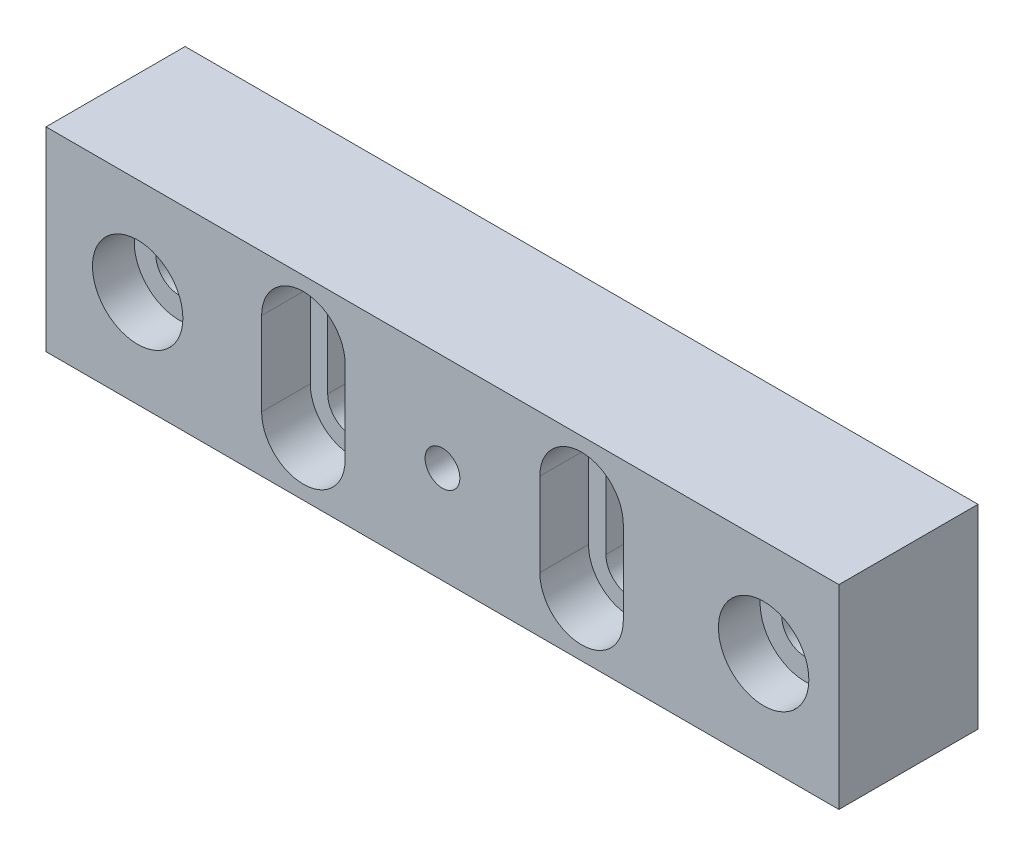
from build123d import *

# Parameters (mm, degrees)
SKETCH1_W                      = 57
SKETCH1_H                      = 14
BOSS_EXTRUDE1_DEPTH            = 10
CUT_EXTRUDE1_DEPTH             = 3.5
CUT_EXTRUDE2_DEPTH             = 7.5
CBORE_FOR_M3_SHCS1_D           = 3.4
CBORE_FOR_M3_SHCS1_CBORE_D     = 6.5
CBORE_FOR_M3_SHCS1_CBORE_DEPTH = 3
LPATTERN1_COUNT                = 2
LPATTERN1_PITCH                = 45
M3X0_5_TAPPED_HOLE1_D          = 2.5


with BuildPart() as part:
    # Sketch1 → Boss-Extrude1 (new body)
    with BuildSketch(Plane.XY):
        Rectangle(SKETCH1_W, SKETCH1_H)
    extrude(amount=BOSS_EXTRUDE1_DEPTH)

    # Sketch2 → Cut-Extrude1 (cut)
    with BuildSketch(Plane.XY.offset(10)):
        with BuildLine():
            Line((-7, 3), (-7, -3))
            ThreePointArc((-7, -3), (-10, -6), (-13, -3))
            Line((-13, -3), (-13, 3))
            ThreePointArc((-13, 3), (-10, 6), (-7, 3))
        make_face()
        with BuildLine():
            Line((13, 3), (13, -3))
            ThreePointArc((13, -3), (10, -6), (7, -3))
            Line((7, -3), (7, 3))
            ThreePointArc((7, 3), (10, 6), (13, 3))
        make_face()
    extrude(amount=-CUT_EXTRUDE1_DEPTH, mode=Mode.SUBTRACT)

    # Sketch3 → Cut-Extrude2 (cut, through all)
    with BuildSketch(Plane.XY.offset(6.5)):
        with BuildLine():
            Line((-11.75, 3), (-11.75, -3))
            ThreePointArc((-11.75, -3), (-10, -4.75), (-8.25, -3))
            Line((-8.25, -3), (-8.25, 3))
            ThreePointArc((-8.25, 3), (-10, 4.75), (-11.75, 3))
        make_face()
        with BuildLine():
            Line((11.75, -3), (11.75, 3))
            ThreePointArc((11.75, 3), (10, 4.75), (8.25, 3))
            Line((8.25, 3), (8.25, -3))
            ThreePointArc((8.25, -3), (10, -4.75), (11.75, -3))
        make_face()
    extrude(amount=-CUT_EXTRUDE2_DEPTH, mode=Mode.SUBTRACT)

    # CBORE for M3 SHCS1 (through all)
    with Locations(Plane.XY.offset(10)):
        with Locations((-21.910027568, 0)):
            cbore_for_m3_shcs1 = CounterBoreHole(CBORE_FOR_M3_SHCS1_D / 2, CBORE_FOR_M3_SHCS1_CBORE_D / 2, CBORE_FOR_M3_SHCS1_CBORE_DEPTH)

    # LPattern1: CBORE for M3 SHCS1 ×2
    with Locations(*[(i * LPATTERN1_PITCH, 0, 0) for i in range(1, LPATTERN1_COUNT)]):
        add(cbore_for_m3_shcs1, mode=Mode.SUBTRACT)

    # M3x0.5 Tapped Hole1 (through all)
    with Locations(Plane.XY.offset(10)):
        with Locations((0, 0)):
            Hole(M3X0_5_TAPPED_HOLE1_D / 2)


solid = part.part
